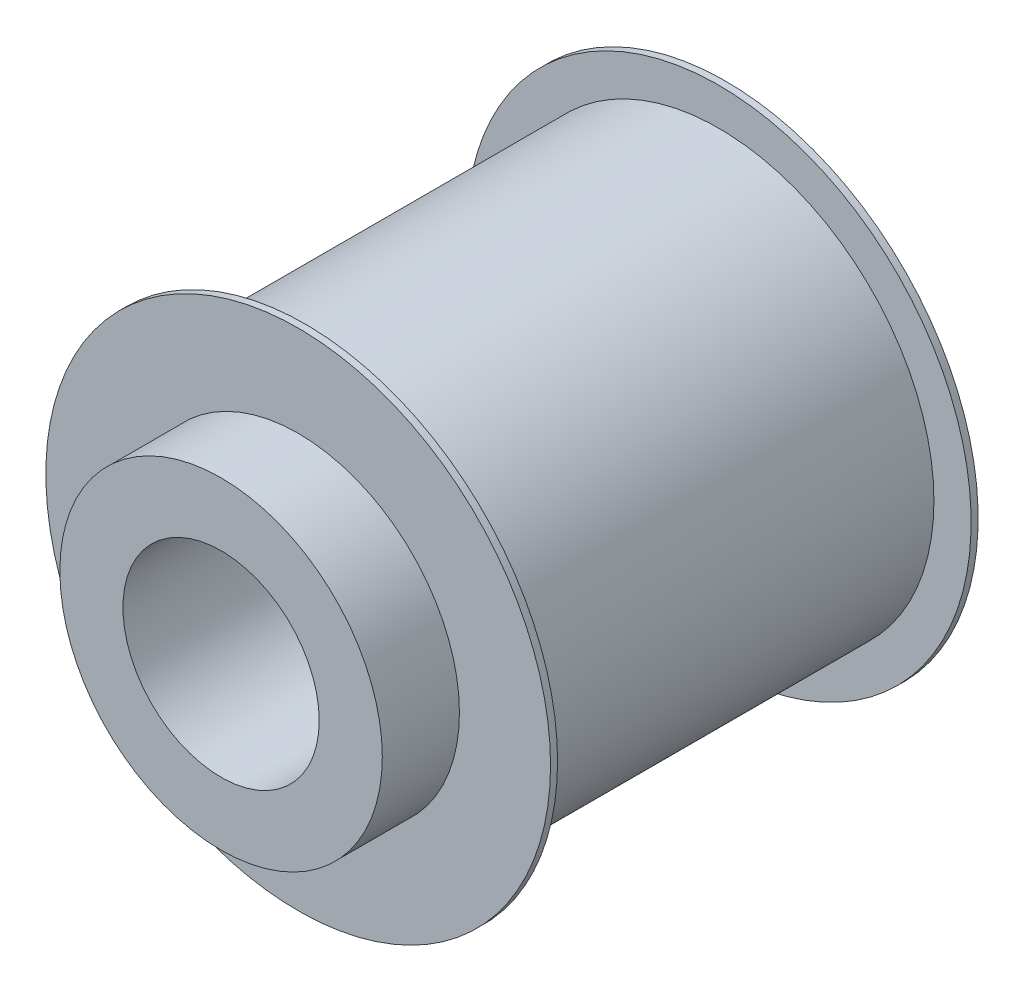
from build123d import *

# Parameters (mm, degrees)
SZKIC1_R                    = 15.345
DODANIE_WYCI_GNI_CIE1_DEPTH = 30.5
SZKIC2_R                    = 11.5
DODANIE_WYCI_GNI_CIE2_DEPTH = 5.5
SZKIC3_R                    = 18
DODANIE_WYCI_GNI_CIE3_DEPTH = 0.5
SZKIC9_R                    = 18
DODANIE_WYCI_GNI_CIE6_DEPTH = 0.5
SZKIC6_R                    = 7
WYTNIJ_WYCI_GNI_CIE1_DEPTH  = 37


with BuildPart() as part:
    # Szkic1 → Dodanie-wyciągnięcie1 (new body)
    with BuildSketch(Plane.XY):
        Circle(SZKIC1_R)
    extrude(amount=DODANIE_WYCI_GNI_CIE1_DEPTH)

    # Szkic2 → Dodanie-wyciągnięcie2 (add)
    with BuildSketch(Plane.XY.offset(30.5)):
        Circle(SZKIC2_R)
    extrude(amount=DODANIE_WYCI_GNI_CIE2_DEPTH)

    # Szkic3 → Dodanie-wyciągnięcie3 (add)
    with BuildSketch(Plane.XY.offset(30.5)):
        Circle(SZKIC3_R)
    extrude(amount=-DODANIE_WYCI_GNI_CIE3_DEPTH)

    # Szkic9 → Dodanie-wyciągnięcie6 (add)
    with BuildSketch(Plane(origin=(0, 0, 0), x_dir=(-1, 0, 0), z_dir=(0, 0, -1))):
        Circle(SZKIC9_R)
    extrude(amount=-DODANIE_WYCI_GNI_CIE6_DEPTH)

    # Szkic6 → Wytnij-wyciągnięcie1 (cut, through all)
    with BuildSketch(Plane.XY.offset(36)):
        Circle(SZKIC6_R)
    extrude(amount=-WYTNIJ_WYCI_GNI_CIE1_DEPTH, mode=Mode.SUBTRACT)


solid = part.part
